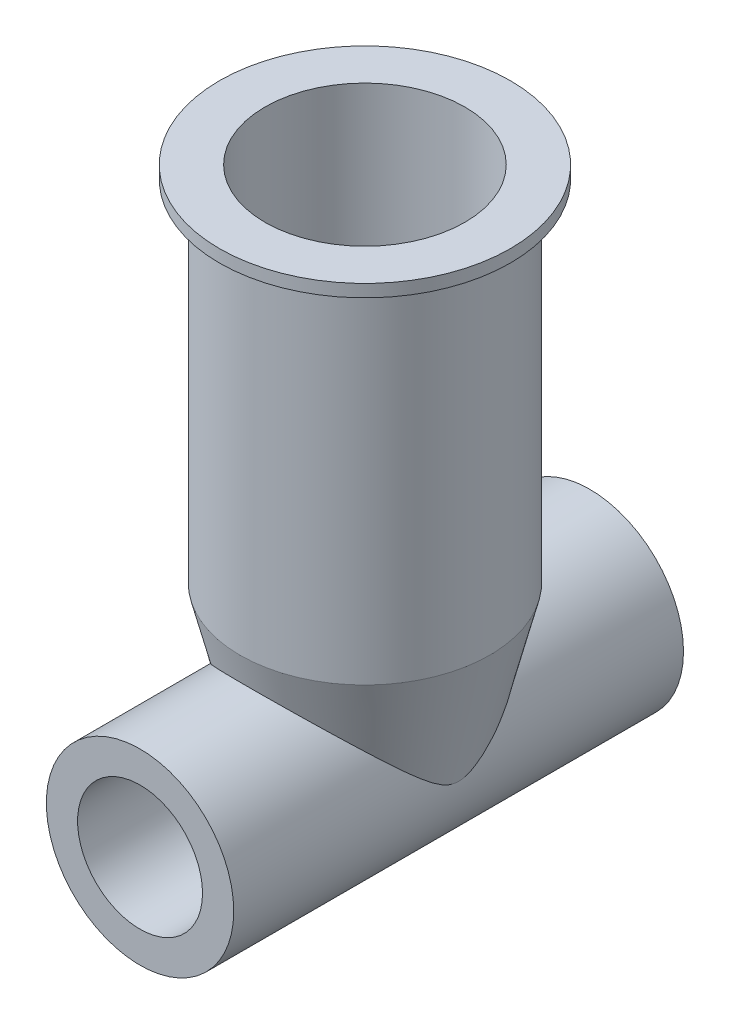
from build123d import *

# Parameters (mm, degrees)
SKETCH1_R                = 7.5
SKETCH1_R_2              = 5
BOSS_EXTRUDE1_DEPTH      = 18
BOSS_EXTRUDE1_DEPTH_BACK = 18
SKETCH3_R                = 10
SKETCH2_R                = 7.5
SKETCH4_R                = 10
SKETCH4_R_2              = 8
BOSS_EXTRUDE3_DEPTH      = 28
SKETCH5_R                = 11.643608711
SKETCH5_R_2              = 8
BOSS_EXTRUDE4_DEPTH      = 1


with BuildPart() as part:
    # Sketch1 → Boss-Extrude1 (new body, two sides)
    with BuildSketch(Plane.XY) as boss_extrude1_sk:
        Circle(SKETCH1_R)
        Circle(SKETCH1_R_2, mode=Mode.SUBTRACT)
    extrude(amount=BOSS_EXTRUDE1_DEPTH)
    extrude(boss_extrude1_sk.sketch, amount=-BOSS_EXTRUDE1_DEPTH_BACK)

    # Sketch3 → Loft1 section 0
    with BuildSketch(Plane(origin=(0, 10, 0), x_dir=(1, 0, 0), z_dir=(0, 1, 0))):
        Circle(SKETCH3_R)
    # Sketch2 → Loft1 section 1
    with BuildSketch(Plane(origin=(0, 0, 0), x_dir=(1, 0, 0), z_dir=(0, 1, 0))):
        Circle(SKETCH2_R)
    loft()

    # Sketch4 → Boss-Extrude3 (add)
    with BuildSketch(Plane(origin=(0, 10, 0), x_dir=(1, 0, 0), z_dir=(0, 1, 0))):
        Circle(SKETCH4_R)
        Circle(SKETCH4_R_2, mode=Mode.SUBTRACT)
    extrude(amount=BOSS_EXTRUDE3_DEPTH)

    # Sketch5 → Boss-Extrude4 (add)
    with BuildSketch(Plane(origin=(0, 38, 0), x_dir=(1, 0, 0), z_dir=(0, 1, 0))):
        Circle(SKETCH5_R)
        Circle(SKETCH5_R_2, mode=Mode.SUBTRACT)
    extrude(amount=BOSS_EXTRUDE4_DEPTH)


solid = part.part
